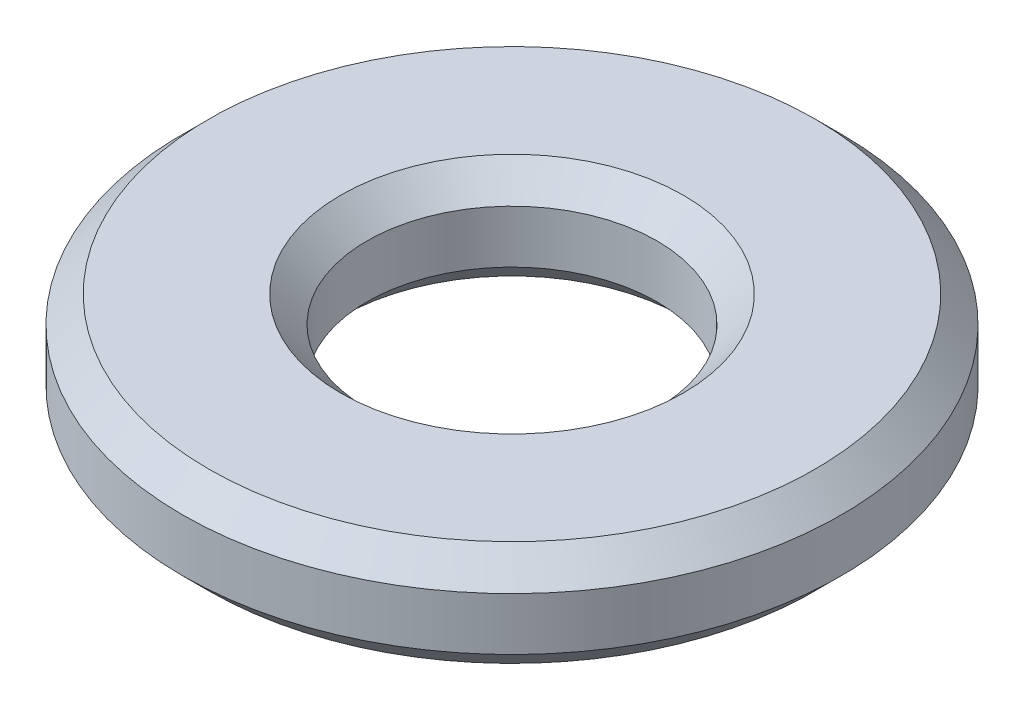
from build123d import *

# Parameters (mm, degrees)
CROQUIS1_R              = 2.5
CROQUIS1_R_2            = 1.1
SALIENTE_EXTRUIR1_DEPTH = 0.8
CHAFL_N1_SIZE           = 0.2


with BuildPart() as part:
    # Croquis1 → Saliente-Extruir1 (new body)
    with BuildSketch(Plane(origin=(0, 0, 0), x_dir=(1, 0, 0), z_dir=(0, 1, 0))):
        Circle(CROQUIS1_R)
        Circle(CROQUIS1_R_2, mode=Mode.SUBTRACT)
    extrude(amount=SALIENTE_EXTRUIR1_DEPTH)

    # Chaflán1
    chafl_n1_edges = [part.edges().sort_by_distance(p)[0] for p in [
        (-2.5, 0, 0),
        (-2.5, 0.8, 0),
        (-1.1, 0, 0),
        (-1.1, 0.8, 0),
    ]]
    chamfer(chafl_n1_edges, length=CHAFL_N1_SIZE)


solid = part.part
